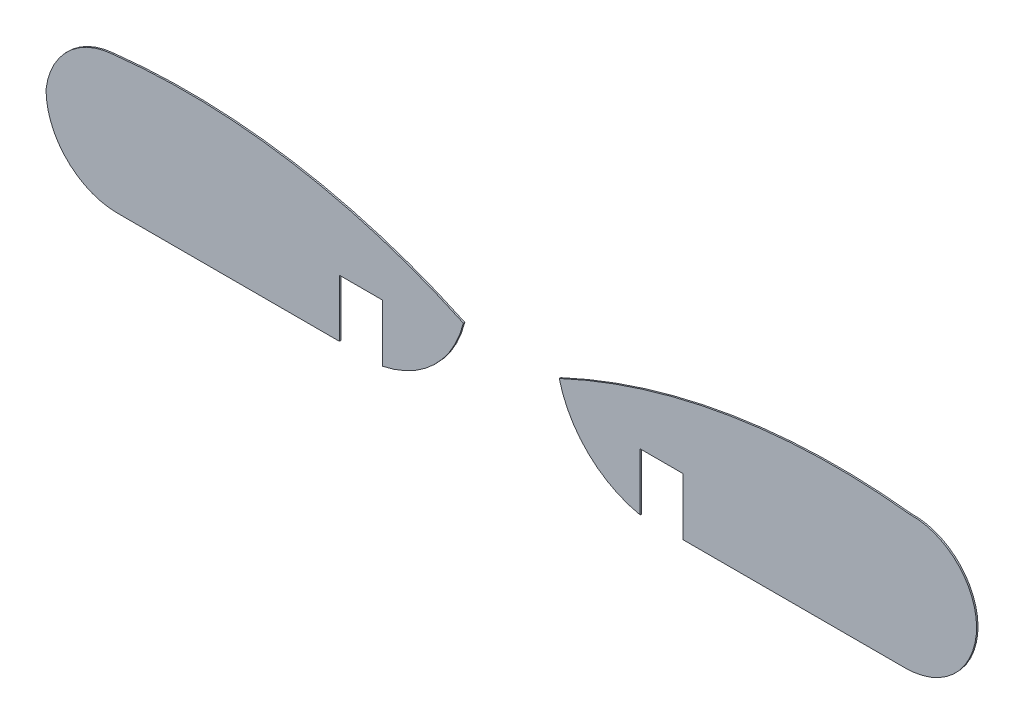
from build123d import *

# Parameters (mm, degrees)
SALIENTE_EXTRUIR1_DEPTH   = 0.1
SALIENTE_EXTRUIR1_2_DEPTH = 0.1


with BuildPart() as part:
    # Model → Saliente-Extruir1 (new body)
    with BuildSketch(Plane.XY):
        with BuildLine():
            Line((14.298081521, -28.740255232), (14.298081521, -32.740255232))
            ThreePointArc((14.298081521, -32.740255232), (17.909033692, -30.841353282), (19.949395844, -27.308404586))
            ThreePointArc((19.949395844, -27.308404586), (7.985017637, -23.599365404), (-4.537175356, -23.286315593))
            ThreePointArc((-4.537175356, -23.286315593), (-7.665621003, -24.679493884), (-9.20203301, -27.740140231))
            ThreePointArc((-9.20203301, -27.740140231), (-7.737607575, -31.275748479), (-4.202033011, -32.740255232))
            Line((-4.202033011, -32.740255232), (11.298081521, -32.740255232))
            Line((11.298081521, -32.740255232), (11.298081521, -28.740255232))
            Line((11.298081521, -28.740255232), (14.298081521, -28.740255232))
        make_face()
    extrude(amount=SALIENTE_EXTRUIR1_DEPTH)


with BuildPart() as body_2:
    # Model → Saliente-Extruir1 2 (new body)
    with BuildSketch(Plane.XY):
        with BuildLine():
            Line((35.298081521, -32.740255232), (50.798196053, -32.740255232))
            ThreePointArc((50.798196053, -32.740255232), (53.939396867, -31.630352589), (55.686026846, -28.79339821))
            ThreePointArc((55.686026846, -28.79339821), (54.763493082, -24.920665912), (51.133338397, -23.286315593))
            ThreePointArc((51.133338397, -23.286315593), (38.611145405, -23.599365404), (26.646767198, -27.308404586))
            ThreePointArc((26.646767198, -27.308404586), (28.68712935, -30.841353282), (32.298081521, -32.740255232))
            Line((32.298081521, -32.740255232), (32.298081521, -28.740255232))
            Line((32.298081521, -28.740255232), (35.298081521, -28.740255232))
            Line((35.298081521, -28.740255232), (35.298081521, -32.740255232))
        make_face()
    extrude(amount=SALIENTE_EXTRUIR1_2_DEPTH)


solid = Compound([part.part, body_2.part])
